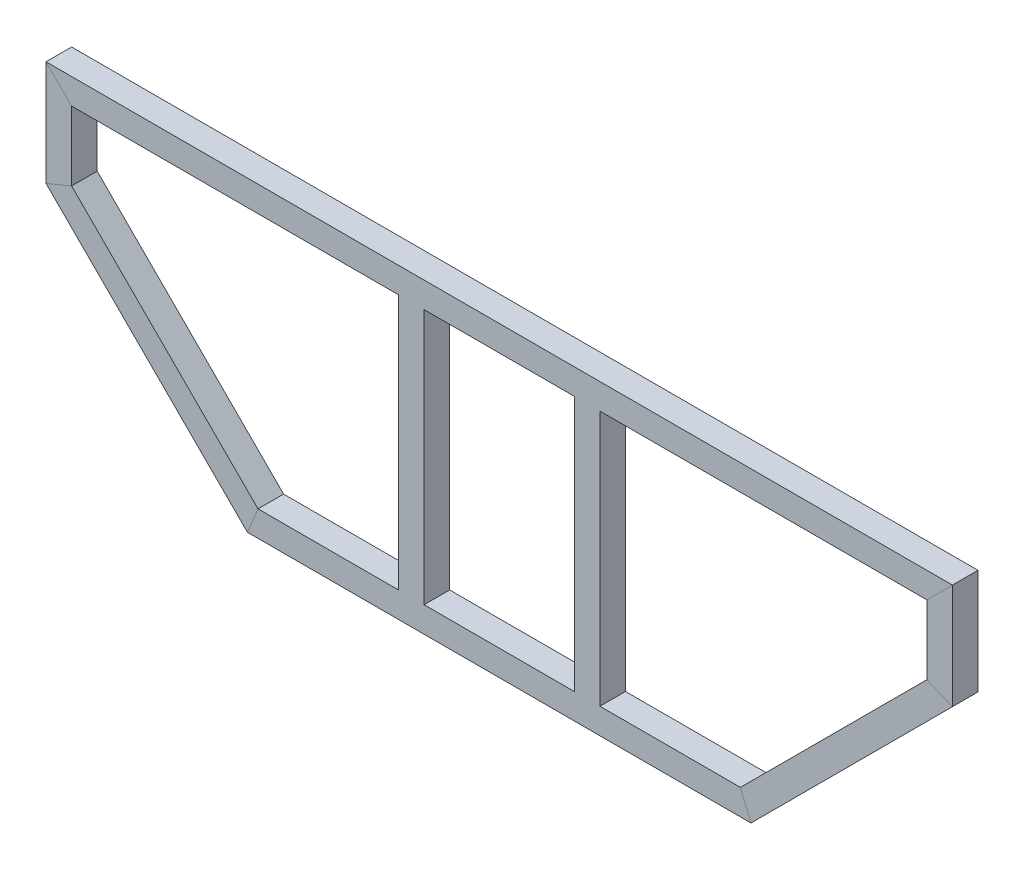
from build123d import *

# Parameters (mm, degrees)
SKETCH4_W           = 25.4
SKETCH4_H           = 25.4
SKETCH4_W_2         = 23
SKETCH4_H_2         = 23
SKETCH5_W           = 25.4
SKETCH5_H           = 25.4
SKETCH5_W_2         = 23
SKETCH5_H_2         = 23
BOSS_EXTRUDE2_DEPTH = 253.8


with BuildPart() as part:
    # Sweep1: sweep along a path in Sketch3
    with BuildLine(Plane.XY) as sweep1_path:
        Line((-250, -304.6), (250, -304.6))
        Line((250, -304.6), (450, -104.6))
        Line((450, -104.6), (450, 0))
        Line((450, 0), (-450, 0))
        Line((-450, 0), (-450, -104.6))
        Line((-450, -104.6), (-250, -304.6))
    # Sketch4 → Sweep1 (sweep)
    with BuildSketch(Plane(origin=(0, 0, 0), x_dir=(0, 0, -1), z_dir=(1, 0, 0))):
        with Locations((12.7, -291.9)):
            Rectangle(SKETCH4_W, SKETCH4_H)
        with Locations((12.7, -291.9)):
            Rectangle(SKETCH4_W_2, SKETCH4_H_2, mode=Mode.SUBTRACT)
    sweep(path=sweep1_path.line, transition=Transition.RIGHT)

    # Sketch5 → Boss-Extrude2 (add)
    with BuildSketch(Plane(origin=(-272.712994231, -279.2, 0), x_dir=(-1, 0, 0), z_dir=(0, 1, 0))):
        with Locations((-360.012994231, -12.7)):
            Rectangle(SKETCH5_W, SKETCH5_H)
        with Locations((-360.012994231, -12.7)):
            Rectangle(SKETCH5_W_2, SKETCH5_H_2, mode=Mode.SUBTRACT)
        with Locations((-185.412994231, -12.7)):
            Rectangle(SKETCH5_W, SKETCH5_H)
        with Locations((-185.412994231, -12.7)):
            Rectangle(SKETCH5_W_2, SKETCH5_H_2, mode=Mode.SUBTRACT)
    extrude(amount=BOSS_EXTRUDE2_DEPTH)


solid = part.part
